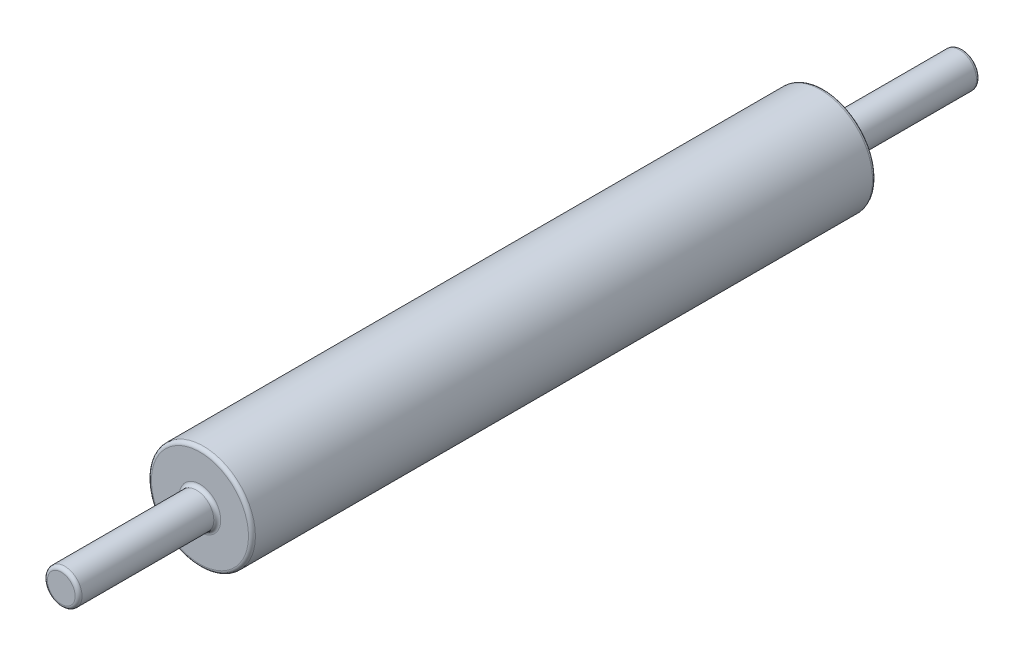
from build123d import *

# Parameters (mm, degrees)
SKETCH1_R           = 38.1
BOSS_EXTRUDE1_DEPTH = 457.2
SKETCH2_R           = 12.7
BOSS_EXTRUDE2_DEPTH = 101.6
SKETCH3_R           = 12.7
BOSS_EXTRUDE3_DEPTH = 101.6
FILLET1_R           = 2.54
FILLET2_R           = 2.54


with BuildPart() as part:
    # Sketch1 → Boss-Extrude1 (new body)
    with BuildSketch(Plane.XY):
        Circle(SKETCH1_R)
    extrude(amount=BOSS_EXTRUDE1_DEPTH)

    # Sketch2 → Boss-Extrude2 (add)
    with BuildSketch(Plane(origin=(0, 0, 0), x_dir=(-1, 0, 0), z_dir=(0, 0, -1))):
        Circle(SKETCH2_R)
    extrude(amount=BOSS_EXTRUDE2_DEPTH)

    # Sketch3 → Boss-Extrude3 (add)
    with BuildSketch(Plane.XY.offset(457.2)):
        Circle(SKETCH3_R)
    extrude(amount=BOSS_EXTRUDE3_DEPTH)

    # Fillet1
    fillet1_edges = [part.edges().sort_by_distance(p)[0] for p in [
        (-12.7, 0, 457.2),
        (12.7, 0, 0),
    ]]
    fillet(fillet1_edges, radius=FILLET1_R)

    # Fillet2
    fillet2_edges = [part.edges().sort_by_distance(p)[0] for p in [
        (-12.7, 0, 558.8),
        (-38.1, 0, 0),
        (-38.1, 0, 457.2),
        (12.7, 0, -101.6),
    ]]
    fillet(fillet2_edges, radius=FILLET2_R)


solid = part.part
